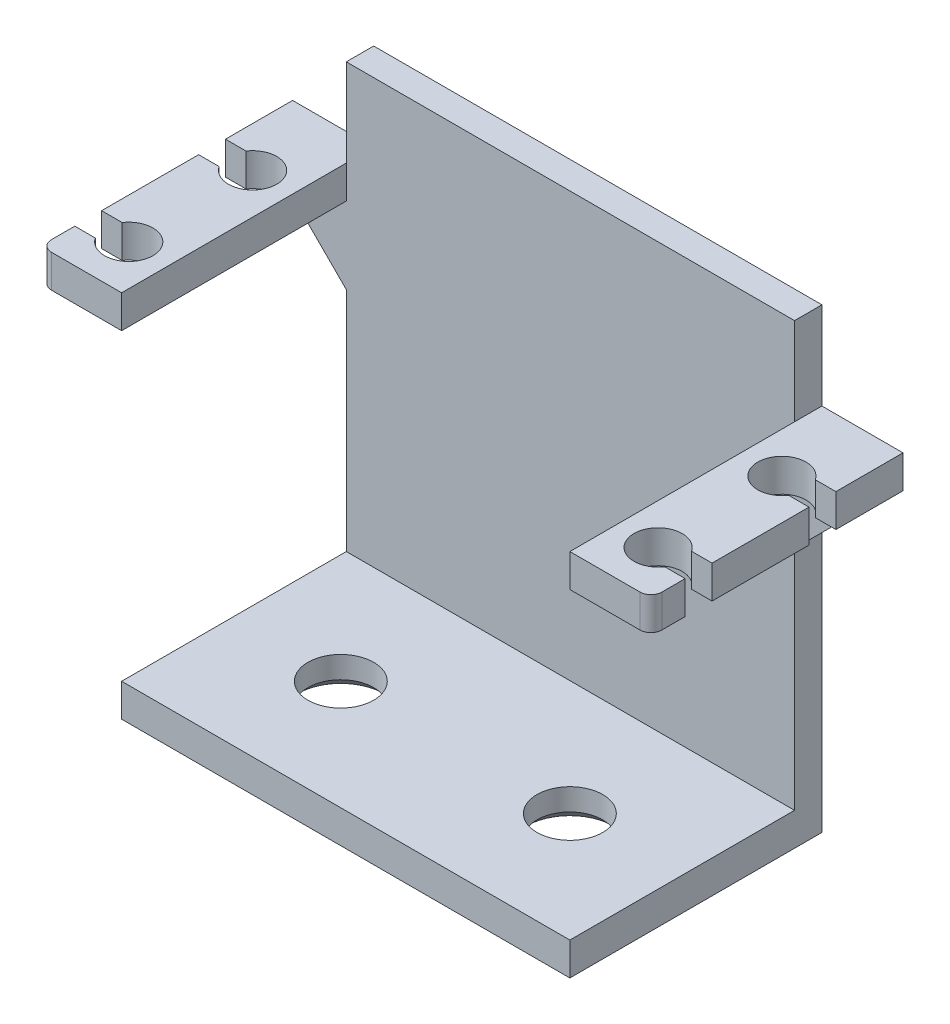
from build123d import *

# Parameters (mm, degrees)
EXTRUDE_2_DEPTH            = 3
SKETCH_4_W                 = 40.9
SKETCH_4_H                 = 2.5
EXTRUDE_3_DEPTH            = 27.7
SKETCH_5_W                 = 40.9
SKETCH_5_H                 = 23
EXTRUDE_4_DEPTH            = 3
CHAMFER_2_SIZE             = 7
SKETCH_8_R                 = 3
CUT_EXTRUDE_3_DEPTH        = 3
CHAMFER_3_SIZE             = 1
CHAMFER_3_OF_MIRROR_1_SIZE = 1
SKETCH_9_W                 = 40.9
SKETCH_9_H                 = 2.5
EXTRUDE_5_DEPTH            = 8


with BuildPart() as part:
    # 스케치3 → 보스-돌출2 (new body)
    with BuildSketch(Plane.XZ.offset(-28.7)):
        with BuildLine():
            Line((-27.85, -6.875), (-27.85, -9))
            Line((-27.85, -9), (-27.85, -13))
            Line((-27.85, -13), (27.85, -13))
            Line((27.85, -13), (27.85, -9))
            Line((27.85, -9), (27.85, -6.875))
            Line((27.85, -6.875), (25.977395688, -6.875))
            ThreePointArc((25.977395688, -6.875), (21.95, -5.65), (25.977395688, -4.425))
            Line((25.977395688, -4.425), (27.85, -4.425))
            Line((27.85, -4.425), (27.85, 4.425))
            Line((27.85, 4.425), (25.977395688, 4.425))
            ThreePointArc((25.977395688, 4.425), (21.95, 5.65), (25.977395688, 6.875))
            Line((25.977395688, 6.875), (27.85, 6.875))
            Line((27.85, 6.875), (27.85, 9))
            ThreePointArc((27.85, 9), (27.557106781, 9.707106781), (26.85, 10))
            Line((26.85, 10), (20.45, 10))
            Line((20.45, 10), (20.45, -10))
            Line((20.45, -10), (20.45, -10.5))
            Line((20.45, -10.5), (-20.45, -10.5))
            Line((-20.45, -10.5), (-20.45, -10))
            Line((-20.45, -10), (-20.45, 10))
            Line((-20.45, 10), (-26.85, 10))
            ThreePointArc((-26.85, 10), (-27.557106781, 9.707106781), (-27.85, 9))
            Line((-27.85, 9), (-27.85, 6.875))
            Line((-27.85, 6.875), (-25.977395688, 6.875))
            ThreePointArc((-25.977395688, 6.875), (-21.95, 5.65), (-25.977395688, 4.425))
            Line((-25.977395688, 4.425), (-27.85, 4.425))
            Line((-27.85, 4.425), (-27.85, -4.425))
            Line((-27.85, -4.425), (-25.977395688, -4.425))
            ThreePointArc((-25.977395688, -4.425), (-21.95, -5.65), (-25.977395688, -6.875))
            Line((-25.977395688, -6.875), (-27.85, -6.875))
        make_face()
    extrude(amount=EXTRUDE_2_DEPTH)

    # 스케치4 → 보스-돌출3 (add)
    with BuildSketch(Plane.XZ.offset(-25.7)):
        with Locations((0, -11.75)):
            Rectangle(SKETCH_4_W, SKETCH_4_H)
    extrude(amount=EXTRUDE_3_DEPTH)

    # 스케치5 → 보스-돌출4 (add)
    with BuildSketch(Plane.XZ.offset(2)):
        with Locations((0, -1.5)):
            Rectangle(SKETCH_5_W, SKETCH_5_H)
    extrude(amount=EXTRUDE_4_DEPTH)

    # 모따기2
    chamfer_2_edges = [part.edges().sort_by_distance(p)[0] for p in [
        (20.45, 25.7, -11.75),
        (-20.45, 25.7, -11.75),
    ]]
    chamfer(chamfer_2_edges, length=CHAMFER_2_SIZE)

    # 스케치8 → 컷-돌출3 (cut)
    with BuildSketch(Plane.XZ.offset(5)):
        with Locations((10.45, 0)):
            Circle(SKETCH_8_R)
    cut_extrude_3 = extrude(amount=-CUT_EXTRUDE_3_DEPTH, mode=Mode.SUBTRACT)

    # 모따기3
    chamfer_3_edges = [part.edges().sort_by_distance(p)[0] for p in [
        (7.45, -5, 0),
    ]]
    chamfer(chamfer_3_edges, length=CHAMFER_3_SIZE)

    # 대칭 복사1: 컷-돌출3 across plane
    add(cut_extrude_3.mirror(Plane(origin=(0, 0, 0), x_dir=(0, 0, 1), z_dir=(1, 0, 0))), mode=Mode.SUBTRACT)

    # 모따기3 of 대칭 복사1
    chamfer_3_of_mirror_1_edges = [part.edges().sort_by_distance(p)[0] for p in [
        (-7.45, -5, 0),
    ]]
    chamfer(chamfer_3_of_mirror_1_edges, length=CHAMFER_3_OF_MIRROR_1_SIZE)

    # 스케치9 → 보스-돌출5 (add)
    with BuildSketch(Plane(origin=(0, 28.7, 0), x_dir=(1, 0, 0), z_dir=(0, 1, 0))):
        with Locations((0, 11.75)):
            Rectangle(SKETCH_9_W, SKETCH_9_H)
    extrude(amount=EXTRUDE_5_DEPTH)


solid = part.part
